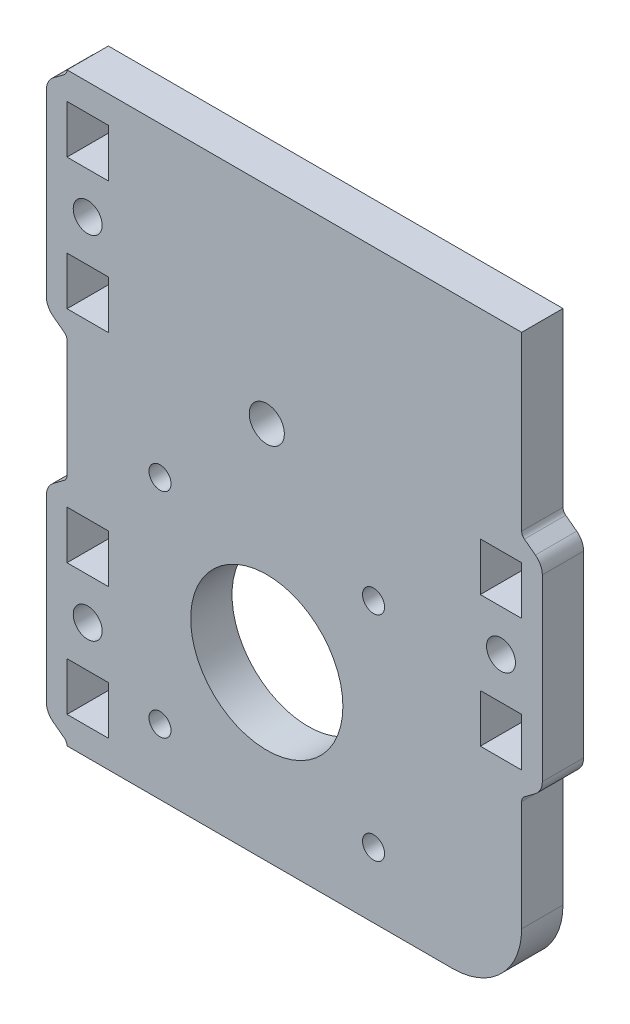
from build123d import *

# Parameters (mm, degrees)
EXTRUDE_1_DEPTH      = 6
SKETCH_2_R           = 11.05
SKETCH_2_R_2         = 1.6
SKETCH_2_R_3         = 2.55
CUT_EXTRUDE_1_DEPTH  = 7
EXTRUDE_2_DEPTH      = 6
SKETCH_3_R           = 2.1
SKETCH_3_W           = 7
SKETCH_3_H           = 6
CUT_EXTRUDE_11_DEPTH = 7
EXTRUDE_21_DEPTH     = 6
SKETCH_31_R          = 2.1
SKETCH_31_W          = 7
SKETCH_31_H          = 6
CUT_EXTRUDE_12_DEPTH = 7
EXTRUDE_24_DEPTH     = 6
SKETCH_34_R          = 2.1
SKETCH_34_W          = 7
SKETCH_34_H          = 6
CUT_EXTRUDE_15_DEPTH = 7


with BuildPart() as part:
    # Эскиз1 → Бобышка-Вытянуть1 (new body)
    with BuildSketch(Plane.XY):
        with BuildLine():
            Line((0, -293.846153846), (66, -293.846153846))
            Line((66, -293.846153846), (66, -368.846153846))
            ThreePointArc((66, -368.846153846), (63.071067812, -375.917221658), (56, -378.846153846))
            Line((56, -378.846153846), (0, -378.846153846))
            Line((0, -378.846153846), (0, -293.846153846))
        make_face()
    extrude(amount=-EXTRUDE_1_DEPTH)

    # Эскиз2 → Вырез-Вытянуть1 (cut, through all)
    with BuildSketch(Plane.XY):
        with Locations((29, -353.846153846)):
            Circle(SKETCH_2_R)
        with Locations((44.5, -369.346153846)):
            Circle(SKETCH_2_R_2)
        with Locations((13.5, -369.346153846)):
            Circle(SKETCH_2_R_2)
        with Locations((13.5, -338.346153846)):
            Circle(SKETCH_2_R_2)
        with Locations((44.5, -338.346153846)):
            Circle(SKETCH_2_R_2)
        with Locations((29, -323.846153846)):
            Circle(SKETCH_2_R_3)
    extrude(amount=-CUT_EXTRUDE_1_DEPTH, mode=Mode.SUBTRACT)

    # Эскиз21 → Бобышка-Вытянуть2 (add)
    with BuildSketch(Plane(origin=(16, -335.846153846, 0), x_dir=(0, 1, 0), z_dir=(0, 0, -1))):
        with BuildLine():
            Line((13, 53), (-13, 53))
            ThreePointArc((-13, 53), (-14.118033989, 52.736067977), (-15, 52))
            Line((-15, 52), (-16.2, 50.4))
            ThreePointArc((-16.2, 50.4), (-16.552786405, 50.105572809), (-17, 50))
            Line((-17, 50), (17, 50))
            ThreePointArc((17, 50), (16.552786405, 50.105572809), (16.2, 50.4))
            Line((16.2, 50.4), (15, 52))
            ThreePointArc((15, 52), (14.118033989, 52.736067977), (13, 53))
        make_face()
    extrude(amount=EXTRUDE_2_DEPTH)

    # Эскиз3 → Вырез-Вытянуть11 (cut, through all)
    with BuildSketch(Plane(origin=(16, -335.846153846, -6), x_dir=(0, 1, 0), z_dir=(0, 0, -1))):
        with Locations((0, 47)):
            Circle(SKETCH_3_R)
        with Locations((9.531849908, 47)):
            Rectangle(SKETCH_3_W, SKETCH_3_H)
        with Locations((-9.531849908, 47)):
            Rectangle(SKETCH_3_W, SKETCH_3_H)
    extrude(amount=-CUT_EXTRUDE_11_DEPTH, mode=Mode.SUBTRACT)

    # Эскиз22 → Бобышка-Вытянуть21 (add)
    with BuildSketch(Plane(origin=(50, -310.846153846, 0), x_dir=(0, -1, 0), z_dir=(0, 0, -1))):
        with BuildLine():
            Line((13, 53), (-13, 53))
            ThreePointArc((-13, 53), (-14.118033989, 52.736067977), (-15, 52))
            Line((-15, 52), (-16.2, 50.4))
            ThreePointArc((-16.2, 50.4), (-16.552786405, 50.105572809), (-17, 50))
            Line((-17, 50), (17, 50))
            ThreePointArc((17, 50), (16.552786405, 50.105572809), (16.2, 50.4))
            Line((16.2, 50.4), (15, 52))
            ThreePointArc((15, 52), (14.118033989, 52.736067977), (13, 53))
        make_face()
    extrude(amount=EXTRUDE_21_DEPTH)

    # Эскиз31 → Вырез-Вытянуть12 (cut, through all)
    with BuildSketch(Plane(origin=(50, -310.846153846, -6), x_dir=(0, -1, 0), z_dir=(0, 0, -1))):
        with Locations((0, 47)):
            Circle(SKETCH_31_R)
        with Locations((9.531849908, 47)):
            Rectangle(SKETCH_31_W, SKETCH_31_H)
        with Locations((-9.531849908, 47)):
            Rectangle(SKETCH_31_W, SKETCH_31_H)
    extrude(amount=-CUT_EXTRUDE_12_DEPTH, mode=Mode.SUBTRACT)

    # Эскиз24 → Бобышка-Вытянуть24 (add)
    with BuildSketch(Plane(origin=(50, -361.846153846, 0), x_dir=(0, -1, 0), z_dir=(0, 0, -1))):
        with BuildLine():
            Line((13, 53), (-13, 53))
            ThreePointArc((-13, 53), (-14.118033989, 52.736067977), (-15, 52))
            Line((-15, 52), (-16.2, 50.4))
            ThreePointArc((-16.2, 50.4), (-16.552786405, 50.105572809), (-17, 50))
            Line((-17, 50), (17, 50))
            ThreePointArc((17, 50), (16.552786405, 50.105572809), (16.2, 50.4))
            Line((16.2, 50.4), (15, 52))
            ThreePointArc((15, 52), (14.118033989, 52.736067977), (13, 53))
        make_face()
    extrude(amount=EXTRUDE_24_DEPTH)

    # Эскиз34 → Вырез-Вытянуть15 (cut, through all)
    with BuildSketch(Plane(origin=(50, -361.846153846, -6), x_dir=(0, -1, 0), z_dir=(0, 0, -1))):
        with Locations((0, 47)):
            Circle(SKETCH_34_R)
        with Locations((9.531849908, 47)):
            Rectangle(SKETCH_34_W, SKETCH_34_H)
        with Locations((-9.531849908, 47)):
            Rectangle(SKETCH_34_W, SKETCH_34_H)
    extrude(amount=-CUT_EXTRUDE_15_DEPTH, mode=Mode.SUBTRACT)


solid = part.part
